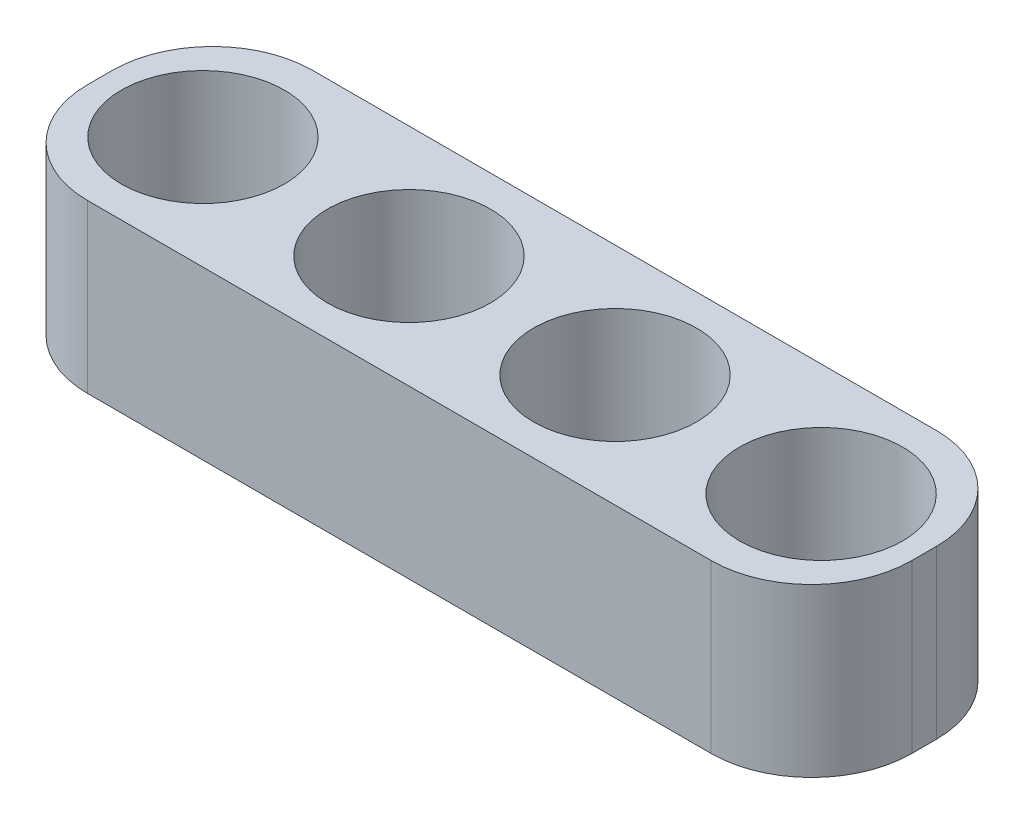
from build123d import *

# Parameters (mm, degrees)
BOSS_EXTRUDE1_DEPTH = 20
FILLET2_R           = 12


with BuildPart() as part:
    # Sketch1 → Boss-Extrude1 (new body)
    with BuildSketch(Plane(origin=(0, 0, 0), x_dir=(1, 0, 0), z_dir=(0, 1, 0))):
        with BuildLine():
            Line((-24.659328932, -13.476609998), (-24.659328932, 13.476609998))
            Line((-24.659328932, 13.476609998), (-49.318657865, 13.476609998))
            Line((-49.318657865, 13.476609998), (-43.570374654, 7.193602767))
            ThreePointArc((-43.570374654, 7.193602767), (-33.058724148, 8.9227509), (-27.238993399, 0))
            ThreePointArc((-27.238993399, 0), (-28.066242499, -3.93026925), (-30.407612143, -7.193602767))
            Line((-30.407612143, -7.193602767), (-24.659328932, -13.476609998))
        make_face()
        with BuildLine():
            Line((-49.318657865, -13.476609998), (-24.659328932, -13.476609998))
            Line((-24.659328932, -13.476609998), (-30.407612143, -7.193602767))
            ThreePointArc((-30.407612143, -7.193602767), (-44.182596166, -6.581381255), (-43.570374654, 7.193602767))
            Line((-43.570374654, 7.193602767), (-49.318657865, 13.476609998))
            Line((-49.318657865, 13.476609998), (-49.318657865, -13.476609998))
        make_face()
        with BuildLine():
            Line((0, -13.476609998), (0, 13.476609998))
            Line((0, 13.476609998), (-24.659328932, 13.476609998))
            Line((-24.659328932, 13.476609998), (-18.911045721, 7.193602767))
            ThreePointArc((-18.911045721, 7.193602767), (-8.399395216, 8.9227509), (-2.579664466, 0))
            ThreePointArc((-2.579664466, 0), (-3.406913566, -3.93026925), (-5.748283211, -7.193602767))
            Line((-5.748283211, -7.193602767), (0, -13.476609998))
        make_face()
        with BuildLine():
            Line((-24.659328932, -13.476609998), (0, -13.476609998))
            Line((0, -13.476609998), (-5.748283211, -7.193602767))
            ThreePointArc((-5.748283211, -7.193602767), (-19.523267233, -6.581381255), (-18.911045721, 7.193602767))
            Line((-18.911045721, 7.193602767), (-24.659328932, 13.476609998))
            Line((-24.659328932, 13.476609998), (-24.659328932, -13.476609998))
        make_face()
        with BuildLine():
            Line((24.659328932, 13.476609998), (0, 13.476609998))
            Line((0, 13.476609998), (5.748283211, 7.193602767))
            ThreePointArc((5.748283211, 7.193602767), (16.259933717, 8.9227509), (22.079664466, 0))
            ThreePointArc((22.079664466, 0), (21.252415366, -3.93026925), (18.911045721, -7.193602767))
            Line((18.911045721, -7.193602767), (24.659328932, -13.476609998))
            Line((24.659328932, -13.476609998), (24.659328932, 13.476609998))
        make_face()
        with BuildLine():
            Line((5.748283211, 7.193602767), (0, 13.476609998))
            Line((0, 13.476609998), (0, -13.476609998))
            Line((0, -13.476609998), (24.659328932, -13.476609998))
            Line((24.659328932, -13.476609998), (18.911045721, -7.193602767))
            ThreePointArc((18.911045721, -7.193602767), (5.136061699, -6.581381255), (5.748283211, 7.193602767))
        make_face()
        with BuildLine():
            Line((49.318657865, 13.476609998), (24.659328932, 13.476609998))
            Line((24.659328932, 13.476609998), (30.407612143, 7.193602767))
            ThreePointArc((30.407612143, 7.193602767), (40.919262649, 8.9227509), (46.738993399, 0))
            ThreePointArc((46.738993399, 0), (45.911744298, -3.93026925), (43.570374654, -7.193602767))
            Line((43.570374654, -7.193602767), (49.318657865, -13.476609998))
            Line((49.318657865, -13.476609998), (49.318657865, 13.476609998))
        make_face()
        with BuildLine():
            Line((30.407612143, 7.193602767), (24.659328932, 13.476609998))
            Line((24.659328932, 13.476609998), (24.659328932, -13.476609998))
            Line((24.659328932, -13.476609998), (49.318657865, -13.476609998))
            Line((49.318657865, -13.476609998), (43.570374654, -7.193602767))
            ThreePointArc((43.570374654, -7.193602767), (29.795390631, -6.581381255), (30.407612143, 7.193602767))
        make_face()
    extrude(amount=BOSS_EXTRUDE1_DEPTH)

    # Fillet2
    fillet2_edges = [part.edges().sort_by_distance(p)[0] for p in [
        (-49.318657865, 10, 13.476609998),
        (-49.318657865, 10, -13.476609998),
        (49.318657865, 10, -13.476609998),
        (49.318657865, 10, 13.476609998),
    ]]
    fillet(fillet2_edges, radius=FILLET2_R)


solid = part.part
